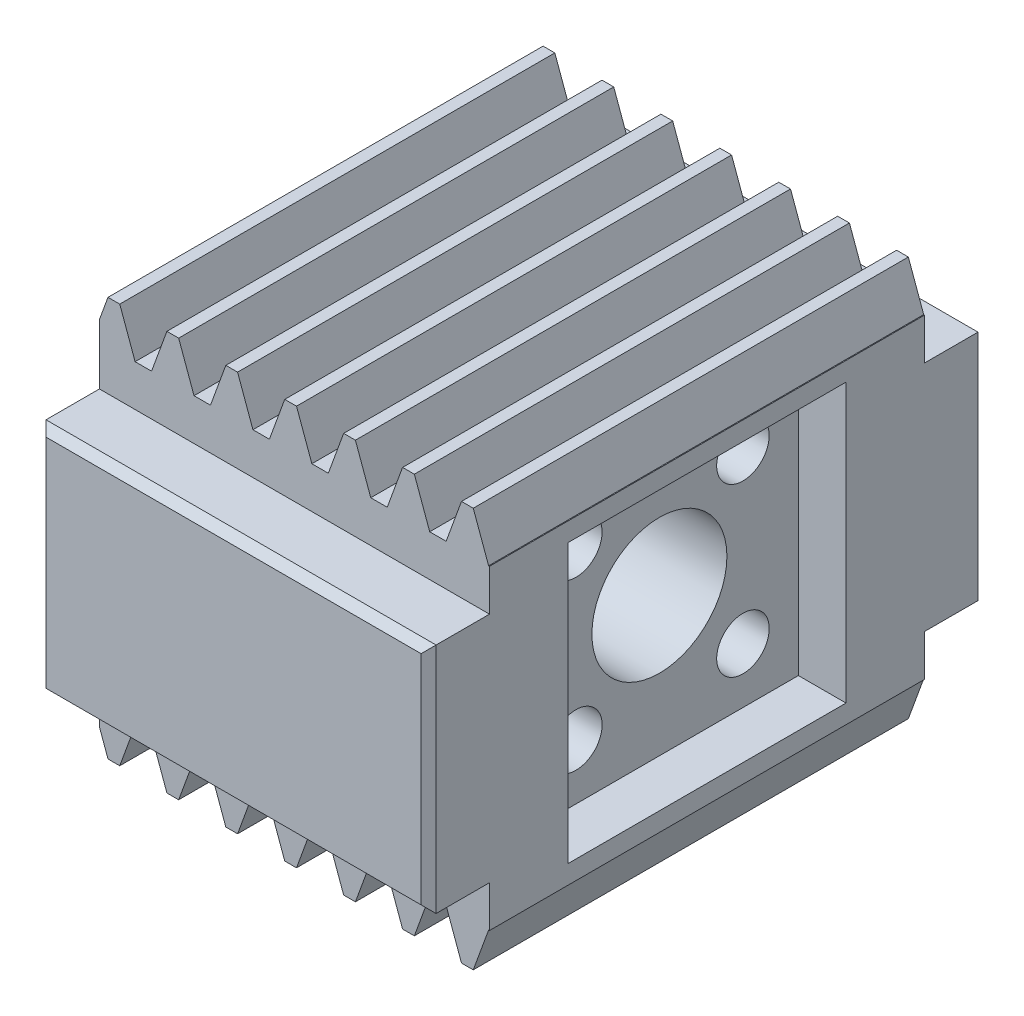
from build123d import *

# Parameters (mm, degrees)
BLANKSKE_W           = 27
BLANKSKE_H           = 13.325
BLANK_DEPTH          = 29
TOOTHCUTSIM_DEPTH    = 42.803775248
TEETHCUTS_COUNT      = 8
TEETHCUTS_PITCH      = 3.926990813
CUT_EXTRUDE1_DEPTH   = 6.75
SKETCH3_R            = 5.25
CUT_EXTRUDE2_DEPTH   = 10.25
SKETCH4_R            = 4.5
CUT_EXTRUDE3_DEPTH   = 37.16013862
SKETCH5_R            = 2.5
CUT_EXTRUDE4_DEPTH   = 3.175
SKETCH6_R            = 1.75
CUT_EXTRUDE5_DEPTH   = 40.826953813
MIRROR1_COPY_1_DEPTH = 42.803775248
MIRROR1_COPY_2_DEPTH = 42.803775248
MIRROR1_COPY_3_DEPTH = 42.803775248
MIRROR1_COPY_4_DEPTH = 42.803775248
MIRROR1_COPY_5_DEPTH = 42.803775248
MIRROR1_COPY_6_DEPTH = 42.803775248
MIRROR1_COPY_7_DEPTH = 42.803775248
SKETCH9_W            = 18.526
SKETCH9_H            = 18.526
CUT_EXTRUDE6_DEPTH   = 3.175
SKETCH10_W           = 4.06
SKETCH10_H           = 15.5
BOSS_EXTRUDE2_DEPTH  = 27
SKETCH12_W           = 29
SKETCH12_H           = 6.213309413
SKETCH12_H_2         = 5.066323004
CUT_EXTRUDE7_DEPTH   = 1
SKETCH12_10_R        = 5.25
SKETCH12_10_R_2      = 1.75
CUT_EXTRUDE8_DEPTH   = 7.75
CUT_EXTRUDE9_START   = -7.75
SKETCH12_11_R        = 5.25
SKETCH12_11_R_2      = 1.75
CUT_EXTRUDE9_DEPTH   = 0.75
CHAMFER1_SIZE        = 0.5


with BuildPart() as part:
    # BlankSke → Blank (new body)
    with BuildSketch(Plane.XY):
        with Locations((13.5, 6.6625)):
            Rectangle(BLANKSKE_W, BLANKSKE_H)
    blank = extrude(amount=-BLANK_DEPTH)

    # TooCutSkeSim → ToothCutSim (cut, through all)
    with BuildSketch(Plane.XY):
        Polygon((0.548044212, 10.5125), (-0.548044212, 10.5125), (-1.58095534, 13.3504), (1.58095534, 13.3504), align=None)
    toothcutsim = extrude(amount=-TOOTHCUTSIM_DEPTH, mode=Mode.SUBTRACT)

    # TeethCuts: ToothCutSim ×8
    with Locations(*[(i * TEETHCUTS_PITCH, 0, 0) for i in range(1, TEETHCUTS_COUNT)]):
        add(toothcutsim, mode=Mode.SUBTRACT)

    # Sketch2 → Cut-Extrude1 (cut)
    with BuildSketch(Plane.ZY):
        with BuildLine():
            Line((-7.445049185, 8.763), (-21.554950815, 8.763))
            ThreePointArc((-21.554950815, 8.763), (-24.647184256, 4.857689952), (-25.75, 0))
            Line((-25.75, 0), (-3.25, 0))
            ThreePointArc((-3.25, 0), (-4.352815744, 4.857689952), (-7.445049185, 8.763))
        make_face()
    cut_extrude1 = extrude(amount=-CUT_EXTRUDE1_DEPTH, mode=Mode.SUBTRACT)

    # Sketch3 → Cut-Extrude2 (cut)
    with BuildSketch(Plane.ZY.offset(-6.75)):
        with Locations((-14.5, 0)):
            Circle(SKETCH3_R)
    cut_extrude2 = extrude(amount=-CUT_EXTRUDE2_DEPTH, mode=Mode.SUBTRACT)

    # Sketch4 → Cut-Extrude3 (cut, symmetric)
    with BuildSketch(Plane.ZY.offset(-17)):
        with Locations((-14.5, 0)):
            Circle(SKETCH4_R)
    cut_extrude3 = extrude(amount=CUT_EXTRUDE3_DEPTH, both=True, mode=Mode.SUBTRACT)

    # Sketch5 → Cut-Extrude4 (cut)
    with BuildSketch(Plane(origin=(27, 0, 0), x_dir=(0, 0, -1), z_dir=(1, 0, 0))):
        with Locations((8.932241205, 5.567758795)):
            Circle(SKETCH5_R)
        with Locations((20.067758795, 5.567758795)):
            Circle(SKETCH5_R)
    cut_extrude4 = extrude(amount=-CUT_EXTRUDE4_DEPTH, mode=Mode.SUBTRACT)

    # Sketch6 → Cut-Extrude5 (cut, through all)
    with BuildSketch(Plane(origin=(23.825, 0, 0), x_dir=(0, 0, -1), z_dir=(1, 0, 0))):
        with Locations((20.067758795, 5.567758795)):
            Circle(SKETCH6_R)
        with Locations((8.932241205, 5.567758795)):
            Circle(SKETCH6_R)
    cut_extrude5 = extrude(amount=-CUT_EXTRUDE5_DEPTH, mode=Mode.SUBTRACT)

    # Mirror1: Blank, ToothCutSim, Cut-Extrude1, Cut-Extrude2, Cut-Extrude3, Cut-Extrude4, Cut-Extrude5 across plane
    add(blank.mirror(Plane(origin=(0, 0, -29), x_dir=(0, 0, 1), z_dir=(0, -1, 0))))
    add(toothcutsim.mirror(Plane(origin=(0, 0, -29), x_dir=(0, 0, 1), z_dir=(0, -1, 0))), mode=Mode.SUBTRACT)
    add(cut_extrude1.mirror(Plane(origin=(0, 0, -29), x_dir=(0, 0, 1), z_dir=(0, -1, 0))), mode=Mode.SUBTRACT)
    add(cut_extrude2.mirror(Plane(origin=(0, 0, -29), x_dir=(0, 0, 1), z_dir=(0, -1, 0))), mode=Mode.SUBTRACT)
    add(cut_extrude3.mirror(Plane(origin=(0, 0, -29), x_dir=(0, 0, 1), z_dir=(0, -1, 0))), mode=Mode.SUBTRACT)
    add(cut_extrude4.mirror(Plane(origin=(0, 0, -29), x_dir=(0, 0, 1), z_dir=(0, -1, 0))), mode=Mode.SUBTRACT)
    add(cut_extrude5.mirror(Plane(origin=(0, 0, -29), x_dir=(0, 0, 1), z_dir=(0, -1, 0))), mode=Mode.SUBTRACT)

    # Mirror1 copy 1 sketch → Mirror1 copy 1 (cut, through all)
    with BuildSketch(Plane(origin=(3.926990813, 0, 0), x_dir=(1, 0, 0), z_dir=(0, 0, 1))):
        Polygon((0.548044212, -10.5125), (-0.548044212, -10.5125), (-1.58095534, -13.3504), (1.58095534, -13.3504), align=None)
    extrude(amount=-MIRROR1_COPY_1_DEPTH, mode=Mode.SUBTRACT)

    # Mirror1 copy 2 sketch → Mirror1 copy 2 (cut, through all)
    with BuildSketch(Plane(origin=(7.853981625, 0, 0), x_dir=(1, 0, 0), z_dir=(0, 0, 1))):
        Polygon((0.548044212, -10.5125), (-0.548044212, -10.5125), (-1.58095534, -13.3504), (1.58095534, -13.3504), align=None)
    extrude(amount=-MIRROR1_COPY_2_DEPTH, mode=Mode.SUBTRACT)

    # Mirror1 copy 3 sketch → Mirror1 copy 3 (cut, through all)
    with BuildSketch(Plane(origin=(11.780972438, 0, 0), x_dir=(1, 0, 0), z_dir=(0, 0, 1))):
        Polygon((0.548044212, -10.5125), (-0.548044212, -10.5125), (-1.58095534, -13.3504), (1.58095534, -13.3504), align=None)
    extrude(amount=-MIRROR1_COPY_3_DEPTH, mode=Mode.SUBTRACT)

    # Mirror1 copy 4 sketch → Mirror1 copy 4 (cut, through all)
    with BuildSketch(Plane(origin=(15.70796325, 0, 0), x_dir=(1, 0, 0), z_dir=(0, 0, 1))):
        Polygon((0.548044212, -10.5125), (-0.548044212, -10.5125), (-1.58095534, -13.3504), (1.58095534, -13.3504), align=None)
    extrude(amount=-MIRROR1_COPY_4_DEPTH, mode=Mode.SUBTRACT)

    # Mirror1 copy 5 sketch → Mirror1 copy 5 (cut, through all)
    with BuildSketch(Plane(origin=(19.634954063, 0, 0), x_dir=(1, 0, 0), z_dir=(0, 0, 1))):
        Polygon((0.548044212, -10.5125), (-0.548044212, -10.5125), (-1.58095534, -13.3504), (1.58095534, -13.3504), align=None)
    extrude(amount=-MIRROR1_COPY_5_DEPTH, mode=Mode.SUBTRACT)

    # Mirror1 copy 6 sketch → Mirror1 copy 6 (cut, through all)
    with BuildSketch(Plane(origin=(23.561944875, 0, 0), x_dir=(1, 0, 0), z_dir=(0, 0, 1))):
        Polygon((0.548044212, -10.5125), (-0.548044212, -10.5125), (-1.58095534, -13.3504), (1.58095534, -13.3504), align=None)
    extrude(amount=-MIRROR1_COPY_6_DEPTH, mode=Mode.SUBTRACT)

    # Mirror1 copy 7 sketch → Mirror1 copy 7 (cut, through all)
    with BuildSketch(Plane(origin=(27.488935688, 0, 0), x_dir=(1, 0, 0), z_dir=(0, 0, 1))):
        Polygon((0.548044212, -10.5125), (-0.548044212, -10.5125), (-1.58095534, -13.3504), (1.58095534, -13.3504), align=None)
    extrude(amount=-MIRROR1_COPY_7_DEPTH, mode=Mode.SUBTRACT)

    # Sketch9 → Cut-Extrude6 (cut)
    with BuildSketch(Plane(origin=(27, 0, 0), x_dir=(0, 0, -1), z_dir=(1, 0, 0))):
        with Locations((14.5, 0)):
            Rectangle(SKETCH9_W, SKETCH9_H)
    extrude(amount=-CUT_EXTRUDE6_DEPTH, mode=Mode.SUBTRACT)

    # Sketch10 → Boss-Extrude2 (add, through all)
    with BuildSketch(Plane(origin=(27, 0, 0), x_dir=(0, 0, -1), z_dir=(1, 0, 0))):
        with Locations((31.03, 0)):
            Rectangle(SKETCH10_W, SKETCH10_H)
        with Locations((-2.03, 0)):
            Rectangle(SKETCH10_W, SKETCH10_H)
    extrude(amount=-BOSS_EXTRUDE2_DEPTH)

    # Sketch12 → Cut-Extrude7 (cut)
    with BuildSketch(Plane.ZY):
        with Locations((-14.5, 13.619154707)):
            Rectangle(SKETCH12_W, SKETCH12_H)
        Polygon((0, 10.5125), (-29, 10.5125), (-29, 7.75), (-33.06, 7.75), (-33.06, -7.75), (-29, -7.75), (-29, -10.5125), (0, -10.5125), (0, -7.75), (4.06, -7.75), (4.06, 7.75), (0, 7.75), align=None)
        with BuildLine():
            Line((-21.554950815, 8.763), (-7.445049185, 8.763))
            ThreePointArc((-7.445049185, 8.763), (-3.25, 0), (-7.445049185, -8.763))
            Line((-7.445049185, -8.763), (-21.554950815, -8.763))
            ThreePointArc((-21.554950815, -8.763), (-25.75, 0), (-21.554950815, 8.763))
        make_face(mode=Mode.SUBTRACT)
        with Locations((-14.5, -13.045661502)):
            Rectangle(SKETCH12_W, SKETCH12_H_2)
    extrude(amount=-CUT_EXTRUDE7_DEPTH, mode=Mode.SUBTRACT)

    # Sketch12_10 → Cut-Extrude8 (cut)
    with BuildSketch(Plane.ZY):
        with BuildLine():
            ThreePointArc((-7.445049185, 8.763), (-3.25, 0), (-7.445049185, -8.763))
            Line((-7.445049185, -8.763), (-21.554950815, -8.763))
            ThreePointArc((-21.554950815, -8.763), (-25.75, 0), (-21.554950815, 8.763))
            Line((-21.554950815, 8.763), (-7.445049185, 8.763))
        make_face()
        with Locations((-14.5, 0)):
            Circle(SKETCH12_10_R, mode=Mode.SUBTRACT)
        with Locations(Location((-20.067758795, -5.567758795, 0), (0, 0, 180))):
            Circle(SKETCH12_10_R_2, mode=Mode.SUBTRACT)
        with Locations(Location((-8.932241205, -5.567758795, 0), (0, 0, 180))):
            Circle(SKETCH12_10_R_2, mode=Mode.SUBTRACT)
        with Locations(Location((-8.932241205, 5.567758795, 0), (0, 0, 180))):
            Circle(SKETCH12_10_R_2, mode=Mode.SUBTRACT)
        with Locations(Location((-20.067758795, 5.567758795, 0), (0, 0, 180))):
            Circle(SKETCH12_10_R_2, mode=Mode.SUBTRACT)
    extrude(amount=-CUT_EXTRUDE8_DEPTH, mode=Mode.SUBTRACT)

    # Sketch12_11 → Cut-Extrude9 (cut)
    with BuildSketch(Plane.ZY.offset(CUT_EXTRUDE9_START)):
        with BuildLine():
            ThreePointArc((-7.445049185, 8.763), (-3.25, 0), (-7.445049185, -8.763))
            Line((-7.445049185, -8.763), (-21.554950815, -8.763))
            ThreePointArc((-21.554950815, -8.763), (-25.75, 0), (-21.554950815, 8.763))
            Line((-21.554950815, 8.763), (-7.445049185, 8.763))
        make_face()
        with Locations((-14.5, 0)):
            Circle(SKETCH12_11_R, mode=Mode.SUBTRACT)
        with Locations(Location((-20.067758795, -5.567758795, 0), (0, 0, 180))):
            Circle(SKETCH12_11_R_2, mode=Mode.SUBTRACT)
        with Locations(Location((-8.932241205, -5.567758795, 0), (0, 0, 180))):
            Circle(SKETCH12_11_R_2, mode=Mode.SUBTRACT)
        with Locations(Location((-8.932241205, 5.567758795, 0), (0, 0, 180))):
            Circle(SKETCH12_11_R_2, mode=Mode.SUBTRACT)
        with Locations(Location((-20.067758795, 5.567758795, 0), (0, 0, 180))):
            Circle(SKETCH12_11_R_2, mode=Mode.SUBTRACT)
    extrude(amount=-CUT_EXTRUDE9_DEPTH, mode=Mode.SUBTRACT)

    # Chamfer1
    chamfer1_edges = [part.edges().sort_by_distance(p)[0] for p in [
        (27, 0, -33.06),
        (27, 0, 4.06),
        (14, 7.75, 4.06),
        (14, -7.75, 4.06),
        (14, -7.75, -33.06),
        (14, 7.75, -33.06),
        (1, 0, -33.06),
        (1, 0, 4.06),
    ]]
    chamfer(chamfer1_edges, length=CHAMFER1_SIZE)


solid = part.part
